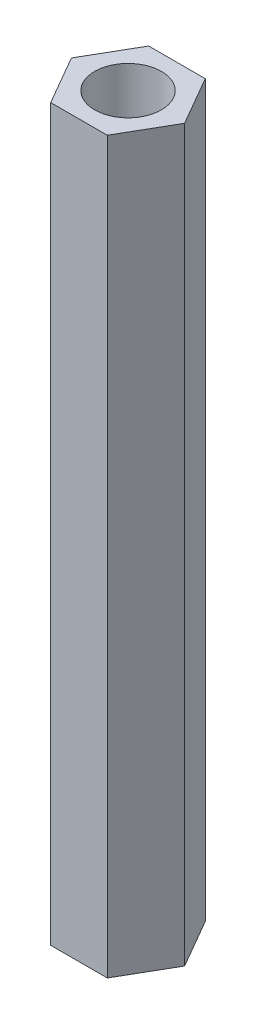
from build123d import *

# Parameters (mm, degrees)
EXTRUDE_1_DEPTH     = 35
SKETCH_2_R          = 1.6
CUT_EXTRUDE_1_DEPTH = 36


with BuildPart() as part:
    # 草图1 → 凸台-拉伸1 (new body)
    with BuildSketch(Plane(origin=(0, 0, 0), x_dir=(1, 0, 0), z_dir=(0, 1, 0))):
        Polygon((2.713546265, 0), (1.356773133, 2.35), (-1.356773133, 2.35), (-2.713546265, 0), (-1.356773133, -2.35), (1.356773133, -2.35), align=None)
    extrude(amount=EXTRUDE_1_DEPTH)

    # 草图2 → 切除-拉伸1 (cut, through all)
    with BuildSketch(Plane(origin=(0, 35, 0), x_dir=(1, 0, 0), z_dir=(0, 1, 0))):
        Circle(SKETCH_2_R)
    extrude(amount=-CUT_EXTRUDE_1_DEPTH, mode=Mode.SUBTRACT)


solid = part.part
